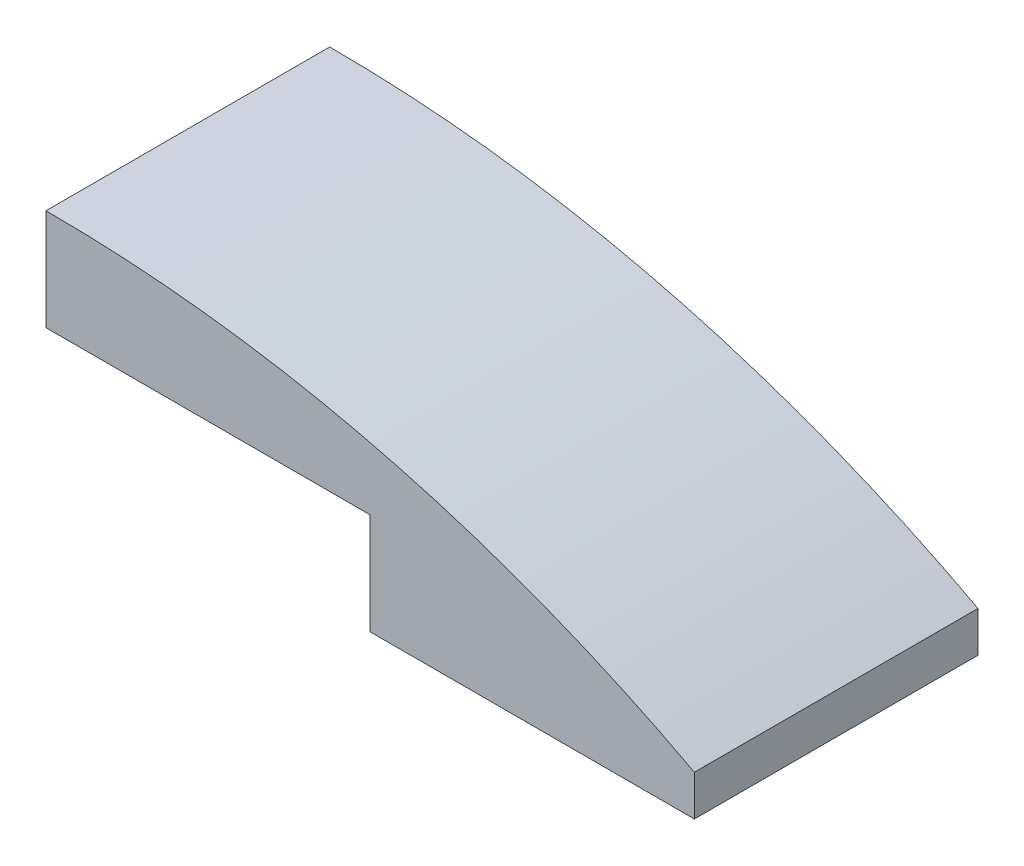
from build123d import *

# Parameters (mm, degrees)
BOSS_EXTRUDE1_DEPTH     = 4.445
CUT_EXTRUDE1_REACH      = 13.535
CUT_EXTRUDE1_END_RADIUS = 41.91
SKETCH2_W               = 9.8425
SKETCH2_H               = 8.255
CUT_EXTRUDE3_REACH      = 14.779
CUT_EXTRUDE3_END_RADIUS = 43.18
SKETCH3_W               = 9.525
SKETCH3_H               = 8.255
BOSS_EXTRUDE2_REACH     = 15.825
SKETCH4_R               = 2.54
SKETCH4_R_2             = 1.905
SKETCH5_W               = 6.203096786
SKETCH5_H               = 3.175
CUT_EXTRUDE4_DEPTH      = 13.197951714
CUT_EXTRUDE4_DEPTH_BACK = 13.197951714


with BuildPart() as part:
    # Sketch1 → Boss-Extrude1 (new, symmetric)
    with BuildSketch(Plane.XY):
        with BuildLine():
            Line((-10.16, 0), (-10.16, 3.175))
            ThreePointArc((-10.16, 3.175), (0.312688289, 1.885753156), (10.16, -1.905))
            Line((10.16, -1.905), (10.16, -3.175))
            Line((10.16, -3.175), (0, -3.175))
            Line((0, -3.175), (0, 0))
            Line((0, 0), (-10.16, 0))
        make_face()
    extrude(amount=BOSS_EXTRUDE1_DEPTH, both=True)

    # Cut-Extrude1: up to this cylinder (the profile starts inside it)
    cut_extrude1_end = Plane(origin=(-10.16, -40.005, 0), z_dir=(0, 0, -1)) * Cylinder(CUT_EXTRUDE1_END_RADIUS, 111.89, mode=Mode.PRIVATE)
    # Sketch2 → Cut-Extrude1 (cut, up to the surface)
    with BuildSketch(Plane.XZ, mode=Mode.PRIVATE) as cut_extrude1_sk1:
        with Locations((-4.92125, 0)):
            Rectangle(SKETCH2_W, SKETCH2_H)
    cut_extrude1_tool1 = extrude(cut_extrude1_sk1.sketch, amount=-CUT_EXTRUDE1_REACH, mode=Mode.PRIVATE) & cut_extrude1_end
    add(cut_extrude1_tool1.solids().sort_by_distance((-4.92125, 0, 0))[0], mode=Mode.SUBTRACT)

    # Cut-Extrude3: up to this cylinder (the profile starts inside it)
    cut_extrude3_end = Plane(origin=(-10.16, -41.275, 0), z_dir=(0, 0, -1)) * Cylinder(CUT_EXTRUDE3_END_RADIUS, 116.918, mode=Mode.PRIVATE)
    # Sketch3 → Cut-Extrude3 (cut, up to the surface)
    with BuildSketch(Plane.XZ.offset(3.175), mode=Mode.PRIVATE) as cut_extrude3_sk1:
        with Locations((5.08, 0)):
            Rectangle(SKETCH3_W, SKETCH3_H)
    cut_extrude3_tool1 = extrude(cut_extrude3_sk1.sketch, amount=-CUT_EXTRUDE3_REACH, mode=Mode.PRIVATE) & cut_extrude3_end
    add(cut_extrude3_tool1.solids().sort_by_distance((5.08, -3.175, 0))[0], mode=Mode.SUBTRACT)

    # Sketch4 → Boss-Extrude2 (add, up to next)
    with BuildSketch(Plane(origin=(0, -5.08, 0), x_dir=(1, 0, 0), z_dir=(0, 1, 0)), mode=Mode.PRIVATE) as boss_extrude2_sk1:
        with Locations(Location((-5.08, 0, 0), (0, 0, 90))):
            Circle(SKETCH4_R)
        with Locations(Location((-5.08, 0, 0), (0, 0, 90))):
            Circle(SKETCH4_R_2, mode=Mode.SUBTRACT)
    boss_extrude2_tool1 = extrude(boss_extrude2_sk1.sketch, amount=BOSS_EXTRUDE2_REACH, mode=Mode.PRIVATE) - part.part
    # Sketch4 → Boss-Extrude2 (add, up to next)
    with BuildSketch(Plane(origin=(0, -5.08, 0), x_dir=(1, 0, 0), z_dir=(0, 1, 0)), mode=Mode.PRIVATE) as boss_extrude2_sk2:
        with Locations(Location((5.08, 0, 0), (0, 0, 90))):
            Circle(SKETCH4_R)
        with Locations(Location((5.08, 0, 0), (0, 0, 90))):
            Circle(SKETCH4_R_2, mode=Mode.SUBTRACT)
    boss_extrude2_tool2 = extrude(boss_extrude2_sk2.sketch, amount=BOSS_EXTRUDE2_REACH, mode=Mode.PRIVATE) - part.part
    add(boss_extrude2_tool1.solids().sort_by_distance((-5.08, -5.08, 2.468158))[0])
    add(boss_extrude2_tool2.solids().sort_by_distance((5.08, -5.08, 2.468158))[0])

    # Sketch5 → Cut-Extrude4 (cut, two sides)
    with BuildSketch(Plane.XY) as cut_extrude4_sk:
        with Locations((-4.842768544, -3.4925)):
            Rectangle(SKETCH5_W, SKETCH5_H)
    extrude(amount=CUT_EXTRUDE4_DEPTH, mode=Mode.SUBTRACT)
    extrude(cut_extrude4_sk.sketch, amount=-CUT_EXTRUDE4_DEPTH_BACK, mode=Mode.SUBTRACT)


solid = part.part
